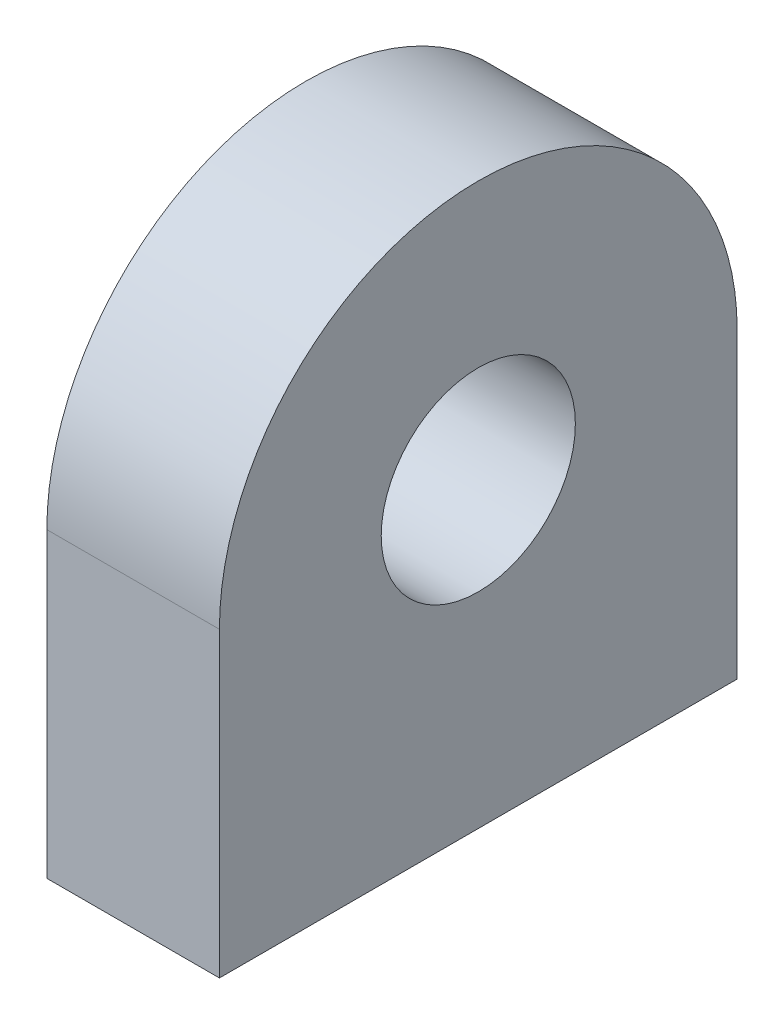
from build123d import *

# Parameters (mm, degrees)
SKETCH1_R           = 14.2875
BOSS_EXTRUDE1_DEPTH = 12.7


with BuildPart() as part:
    # Sketch1 → Boss-Extrude1 (new body, symmetric)
    with BuildSketch(Plane(origin=(0, 0, 0), x_dir=(0, 0, -1), z_dir=(1, 0, 0))):
        with BuildLine():
            Line((-38.1, 0), (38.1, 0))
            Line((38.1, 0), (38.1, 44.45))
            ThreePointArc((38.1, 44.45), (0, 82.55), (-38.1, 44.45))
            Line((-38.1, 44.45), (-38.1, 0))
        make_face()
        with Locations((0, 44.45)):
            Circle(SKETCH1_R, mode=Mode.SUBTRACT)
    extrude(amount=BOSS_EXTRUDE1_DEPTH, both=True)


solid = part.part
